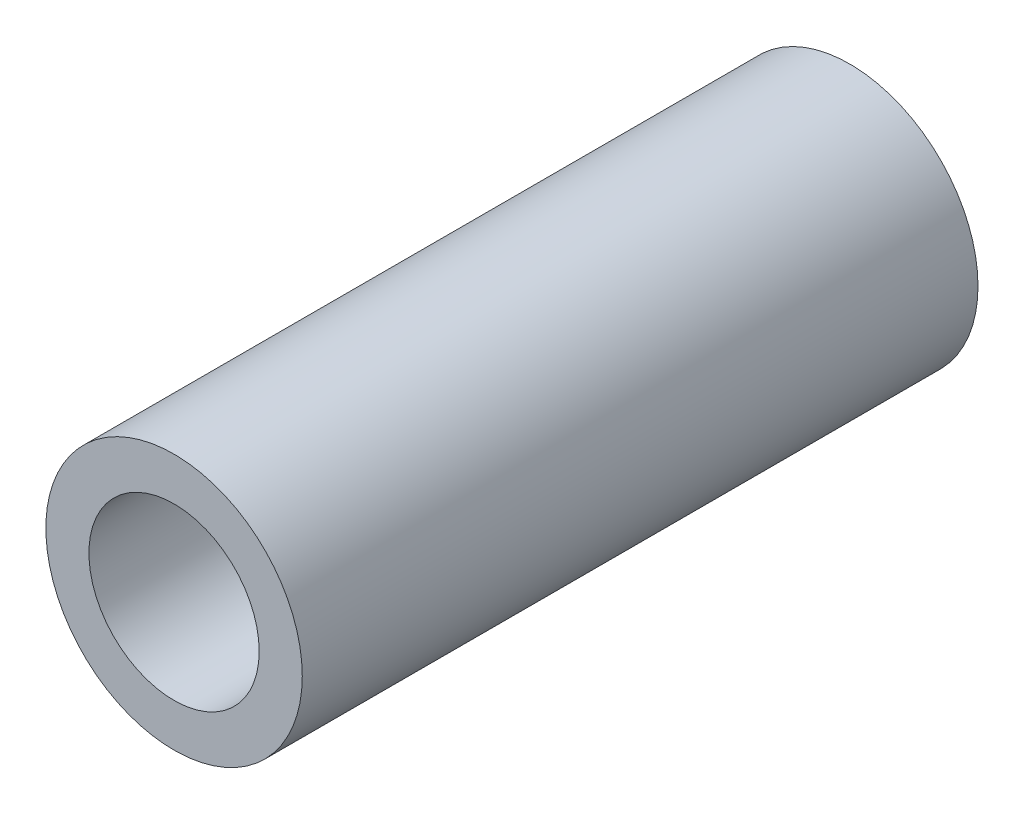
from build123d import *

# Parameters (mm, degrees)
SKETCH3_R           = 2.38125
SKETCH3_R_2         = 1.58125
BOSS_EXTRUDE1_DEPTH = 12.55


with BuildPart() as part:
    # Sketch3 → Boss-Extrude1 (new body)
    with BuildSketch(Plane.XY):
        Circle(SKETCH3_R)
        Circle(SKETCH3_R_2, mode=Mode.SUBTRACT)
    extrude(amount=BOSS_EXTRUDE1_DEPTH)


solid = part.part
